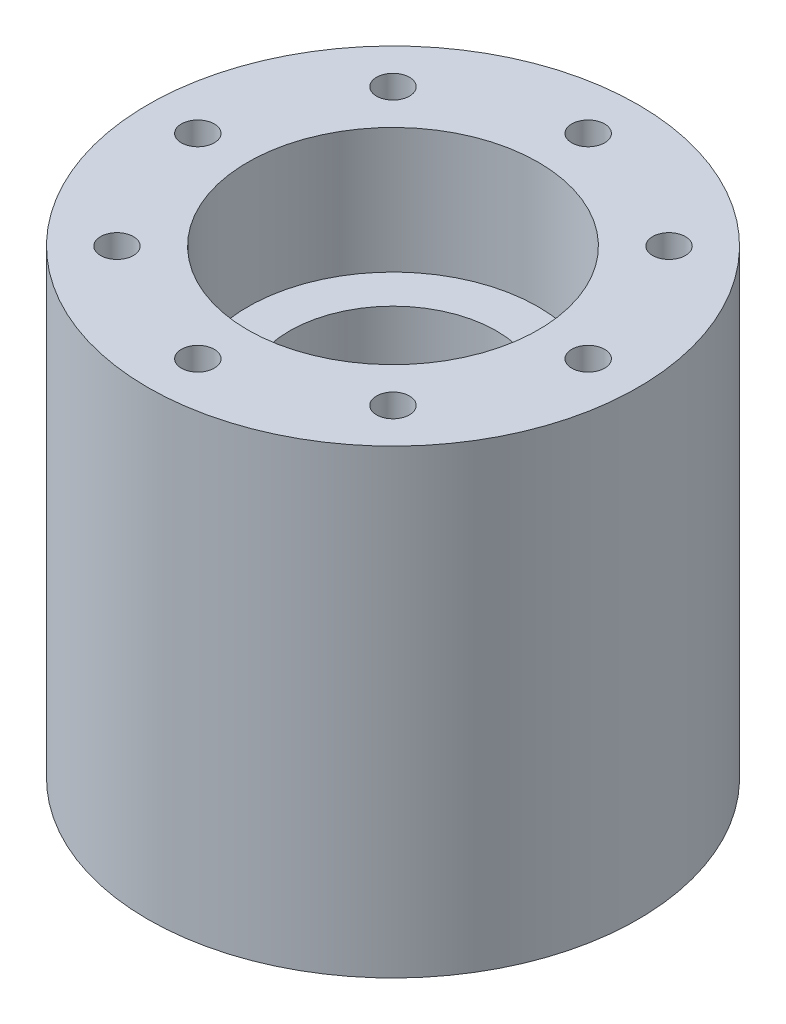
from build123d import *

# Parameters (mm, degrees)
BODY_SKETCH_R              = 18.6375
BODY_EXTRUDE_DEPTH         = 35.03125
BEARING_POCKET_SKETCH_R    = 11.049
BEARING_POCKET_CUT_1_DEPTH = 9.525
BEARING_START              = -35.03125
BEARING_POCKET_SKETCH_2_R  = 11.049
BEARING_POCKET_CUT_2_DEPTH = 9.525
BORE_SKETCH_R              = 7.874
BORE_CUT_DEPTH             = 36.03125
M3X0_5_TAPPED_HOLE1_D      = 2.5
M3X0_5_TAPPED_HOLE1_DEPTH  = 7.50062
M3X0_5_TAPPED_HOLE1_TIP    = 0.751075774
M3X0_5_TAPPED_HOLE3_D      = 2.5
M3X0_5_TAPPED_HOLE3_DEPTH  = 7.50062
M3X0_5_TAPPED_HOLE3_TIP    = 0.751075774


with BuildPart() as part:
    # Body Sketch → Body Extrude (new body)
    with BuildSketch(Plane(origin=(0, 0, 0), x_dir=(1, 0, 0), z_dir=(0, 1, 0))):
        Circle(BODY_SKETCH_R)
    extrude(amount=BODY_EXTRUDE_DEPTH)

    # Bearing Pocket Sketch → Bearing Pocket Cut 1 (cut)
    with BuildSketch(Plane(origin=(0, 0, 0), x_dir=(-1, 0, 0), z_dir=(0, -1, 0))):
        Circle(BEARING_POCKET_SKETCH_R)
    extrude(amount=-BEARING_POCKET_CUT_1_DEPTH, mode=Mode.SUBTRACT)

    # Bearing Pocket Sketch_2 → Bearing Pocket Cut 2 (cut)
    with BuildSketch(Plane(origin=(0, 0, 0), x_dir=(-1, 0, 0), z_dir=(0, -1, 0)).offset(BEARING_START)):
        Circle(BEARING_POCKET_SKETCH_2_R)
    extrude(amount=BEARING_POCKET_CUT_2_DEPTH, mode=Mode.SUBTRACT)

    # Bore Sketch → Bore Cut (cut, through all)
    with BuildSketch(Plane(origin=(0, 0, 0), x_dir=(-1, 0, 0), z_dir=(0, -1, 0))):
        Circle(BORE_SKETCH_R)
    extrude(amount=-BORE_CUT_DEPTH, mode=Mode.SUBTRACT)

    # M3x0.5 Tapped Hole1
    with Locations(Plane(origin=(0, 0, 14.843252), x_dir=(0, 0, -1), z_dir=(0, -1, 0))):
        with Locations((0, 0), (4.347487856, 10.495764144), (14.843252, 14.843252), (25.339016144, 10.495764144), (29.686504, 0), (25.339016144, -10.495764144), (14.843252, -14.843252), (4.347487856, -10.495764144)):
            Hole(M3X0_5_TAPPED_HOLE1_D / 2, depth=M3X0_5_TAPPED_HOLE1_DEPTH)
            with Locations((0, 0, -(M3X0_5_TAPPED_HOLE1_DEPTH + M3X0_5_TAPPED_HOLE1_TIP / 2))):  # 118° drill point
                Cone(0, M3X0_5_TAPPED_HOLE1_D / 2, M3X0_5_TAPPED_HOLE1_TIP, mode=Mode.SUBTRACT)

    # M3x0.5 Tapped Hole3
    with Locations(Plane(origin=(0, 35.03125, 14.843252), x_dir=(0, 0, 1), z_dir=(0, 1, 0))):
        with Locations((0, 0), (-4.347487856, 10.495764144), (-14.843252, 14.843252), (-25.339016144, 10.495764144), (-29.686504, 0), (-25.339016144, -10.495764144), (-14.843252, -14.843252), (-4.347487856, -10.495764144)):
            Hole(M3X0_5_TAPPED_HOLE3_D / 2, depth=M3X0_5_TAPPED_HOLE3_DEPTH)
            with Locations((0, 0, -(M3X0_5_TAPPED_HOLE3_DEPTH + M3X0_5_TAPPED_HOLE3_TIP / 2))):  # 118° drill point
                Cone(0, M3X0_5_TAPPED_HOLE3_D / 2, M3X0_5_TAPPED_HOLE3_TIP, mode=Mode.SUBTRACT)


solid = part.part
